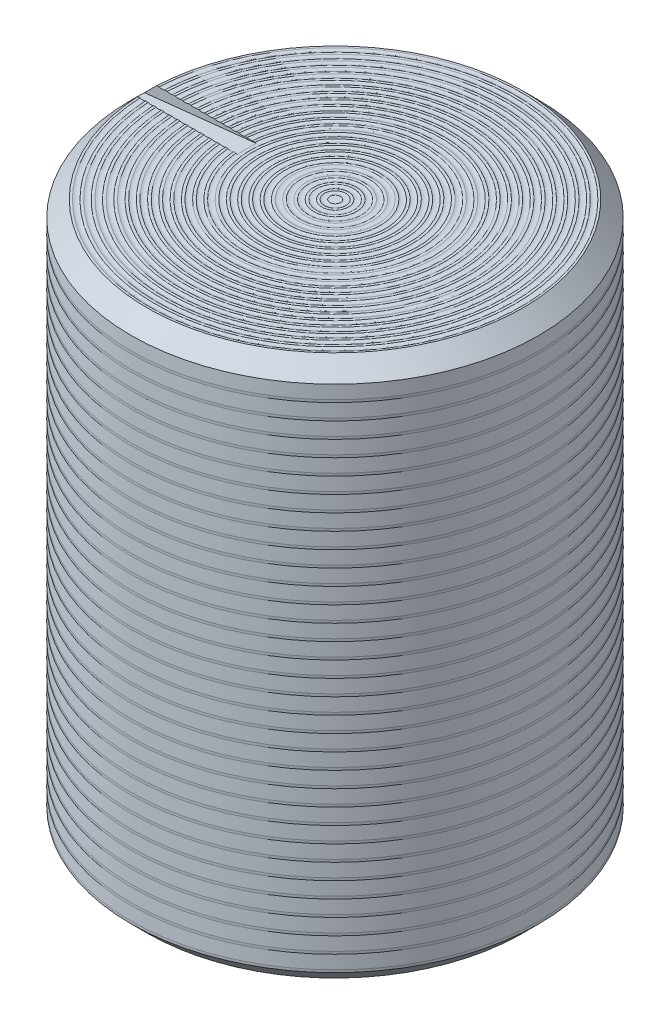
from build123d import *

# Parameters (mm, degrees)
SKETCH1_R           = 6.4
BOSS_EXTRUDE1_DEPTH = 17
CHAMFER1_SIZE       = 0.5
CUT_EXTRUDE1_DEPTH  = 0.3
SKETCH4_R           = 5.5
CUT_EXTRUDE2_DEPTH  = 16.5


with BuildPart() as part:
    # Sketch1 → Boss-Extrude1 (new body)
    with BuildSketch(Plane(origin=(0, 0, 0), x_dir=(1, 0, 0), z_dir=(0, 1, 0))):
        with Locations(Location((0, 0, 0), (0, 0, 270))):
            Circle(SKETCH1_R)
    extrude(amount=BOSS_EXTRUDE1_DEPTH)

    # Chamfer1
    chamfer1_edges = [part.edges().sort_by_distance(p)[0] for p in [
        (0, 0, -6.4),
        (0, 17, -6.4),
    ]]
    chamfer(chamfer1_edges, length=CHAMFER1_SIZE)

    # Sketch2 → Cut-Extrude1 (cut, symmetric)
    with BuildSketch(Plane.XY):
        Polygon((-6.4, 16.6), (-6.4, 17), (-2.65, 17), align=None)
    extrude(amount=CUT_EXTRUDE1_DEPTH, both=True, mode=Mode.SUBTRACT)

    # Sketch3 → Cut-Revolve1 (revolve, cut)
    with BuildSketch(Plane.XY, mode=Mode.PRIVATE) as cut_revolve1_sk:
        Polygon((-6.4, 0.5785964), (-6.367367886, 1), (-6.4, 1), align=None)
        Polygon((-6.4, 1.0785964), (-6.367367886, 1.5), (-6.4, 1.5), align=None)
        Polygon((-6.4, 1.5785964), (-6.367367886, 2), (-6.4, 2), align=None)
        Polygon((-6.4, 2.0785964), (-6.367367886, 2.5), (-6.4, 2.5), align=None)
        Polygon((-6.4, 2.5785964), (-6.367367886, 3), (-6.4, 3), align=None)
        Polygon((-6.4, 3.0785964), (-6.367367886, 3.5), (-6.4, 3.5), align=None)
        Polygon((-6.4, 3.5785964), (-6.367367886, 4), (-6.4, 4), align=None)
        Polygon((-6.4, 4.0785964), (-6.367367886, 4.5), (-6.4, 4.5), align=None)
        Polygon((-6.4, 4.5785964), (-6.367367886, 5), (-6.4, 5), align=None)
        Polygon((-6.4, 5.0785964), (-6.367367886, 5.5), (-6.4, 5.5), align=None)
        Polygon((-6.4, 5.5785964), (-6.367367886, 6), (-6.4, 6), align=None)
        Polygon((-6.4, 6.0785964), (-6.367367886, 6.5), (-6.4, 6.5), align=None)
        Polygon((-6.4, 6.5785964), (-6.367367886, 7), (-6.4, 7), align=None)
        Polygon((-6.4, 7.0785964), (-6.367367886, 7.5), (-6.4, 7.5), align=None)
        Polygon((-6.4, 7.5785964), (-6.367367886, 8), (-6.4, 8), align=None)
        Polygon((-6.4, 8.0785964), (-6.367367886, 8.5), (-6.4, 8.5), align=None)
        Polygon((-6.4, 8.5785964), (-6.367367886, 9), (-6.4, 9), align=None)
        Polygon((-6.4, 9.0785964), (-6.367367886, 9.5), (-6.4, 9.5), align=None)
        Polygon((-6.4, 9.5785964), (-6.367367886, 10), (-6.4, 10), align=None)
        Polygon((-6.4, 10.0785964), (-6.367367886, 10.5), (-6.4, 10.5), align=None)
        Polygon((-6.4, 10.5785964), (-6.367367886, 11), (-6.4, 11), align=None)
        Polygon((-6.4, 11.0785964), (-6.367367886, 11.5), (-6.4, 11.5), align=None)
        Polygon((-6.4, 11.5785964), (-6.367367886, 12), (-6.4, 12), align=None)
        Polygon((-6.4, 12.0785964), (-6.367367886, 12.5), (-6.4, 12.5), align=None)
        Polygon((-6.4, 12.5785964), (-6.367367886, 13), (-6.4, 13), align=None)
        Polygon((-6.4, 13.0785964), (-6.367367886, 13.5), (-6.4, 13.5), align=None)
        Polygon((-6.4, 13.5785964), (-6.367367886, 14), (-6.4, 14), align=None)
        Polygon((-6.4, 14.0785964), (-6.367367886, 14.5), (-6.4, 14.5), align=None)
        Polygon((-6.4, 14.5785964), (-6.367367886, 15), (-6.4, 15), align=None)
        Polygon((-6.4, 15.0785964), (-6.367367886, 15.5), (-6.4, 15.5), align=None)
        Polygon((-6.4, 15.5785964), (-6.367367886, 16), (-6.4, 16), align=None)
        Polygon((-6.4, 16.0785964), (-6.367367886, 16.5), (-6.4, 16.5), align=None)
        Polygon((-6.4, 16.5785964), (-6.367367886, 17), (-6.4, 17), align=None)
        Polygon((-6.4, 17.0785964), (-6.367367886, 17.5), (-6.4, 17.5), align=None)
    revolve(cut_revolve1_sk.sketch.rotate(Axis((0, 0, 0), (0, 1, 0)), 270), axis=Axis((0, 0, 0), (0, 1, 0)), mode=Mode.SUBTRACT)

    # Sketch4 → Cut-Extrude2 (cut)
    with BuildSketch(Plane.XZ):
        with Locations(Location((0, 0, 0), (0, 0, 270))):
            Circle(SKETCH4_R)
    extrude(amount=-CUT_EXTRUDE2_DEPTH, mode=Mode.SUBTRACT)

    # Sketch5 → Cut-Revolve2 (revolve, cut)
    with BuildSketch(Plane.XY):
        with BuildLine():
            Line((0.169631255, 17), (0.3380008, 17))
            add(Edge.make_bspline(
                [(0.169631255, 17), (0.253816027, 16.968101837), (0.3380008, 17)],
                knots=[0, 0, 0, 1, 1, 1], degree=2))
        make_face()
        with BuildLine():
            Line((0.419631255, 17), (0.5880008, 17))
            add(Edge.make_bspline(
                [(0.419631255, 17), (0.503816027, 16.968101837), (0.5880008, 17)],
                knots=[0, 0, 0, 1, 1, 1], degree=2))
        make_face()
        with BuildLine():
            Line((0.669631255, 17), (0.8380008, 17))
            add(Edge.make_bspline(
                [(0.669631255, 17), (0.753816027, 16.968101837), (0.8380008, 17)],
                knots=[0, 0, 0, 1, 1, 1], degree=2))
        make_face()
        with BuildLine():
            Line((0.919631255, 17), (1.0880008, 17))
            add(Edge.make_bspline(
                [(0.919631255, 17), (1.003816027, 16.968101837), (1.0880008, 17)],
                knots=[0, 0, 0, 1, 1, 1], degree=2))
        make_face()
        with BuildLine():
            Line((1.169631255, 17), (1.3380008, 17))
            add(Edge.make_bspline(
                [(1.169631255, 17), (1.253816027, 16.968101837), (1.3380008, 17)],
                knots=[0, 0, 0, 1, 1, 1], degree=2))
        make_face()
        with BuildLine():
            Line((1.419631255, 17), (1.5880008, 17))
            add(Edge.make_bspline(
                [(1.419631255, 17), (1.503816027, 16.968101837), (1.5880008, 17)],
                knots=[0, 0, 0, 1, 1, 1], degree=2))
        make_face()
        with BuildLine():
            Line((1.669631255, 17), (1.8380008, 17))
            add(Edge.make_bspline(
                [(1.669631255, 17), (1.753816027, 16.968101837), (1.8380008, 17)],
                knots=[0, 0, 0, 1, 1, 1], degree=2))
        make_face()
        with BuildLine():
            Line((1.919631255, 17), (2.0880008, 17))
            add(Edge.make_bspline(
                [(1.919631255, 17), (2.003816027, 16.968101837), (2.0880008, 17)],
                knots=[0, 0, 0, 1, 1, 1], degree=2))
        make_face()
        with BuildLine():
            Line((2.169631255, 17), (2.3380008, 17))
            add(Edge.make_bspline(
                [(2.169631255, 17), (2.253816027, 16.968101837), (2.3380008, 17)],
                knots=[0, 0, 0, 1, 1, 1], degree=2))
        make_face()
        with BuildLine():
            Line((2.419631255, 17), (2.5880008, 17))
            add(Edge.make_bspline(
                [(2.419631255, 17), (2.503816027, 16.968101837), (2.5880008, 17)],
                knots=[0, 0, 0, 1, 1, 1], degree=2))
        make_face()
        with BuildLine():
            Line((2.669631255, 17), (2.8380008, 17))
            add(Edge.make_bspline(
                [(2.669631255, 17), (2.753816027, 16.968101837), (2.8380008, 17)],
                knots=[0, 0, 0, 1, 1, 1], degree=2))
        make_face()
        with BuildLine():
            Line((2.919631255, 17), (3.0880008, 17))
            add(Edge.make_bspline(
                [(2.919631255, 17), (3.003816027, 16.968101837), (3.0880008, 17)],
                knots=[0, 0, 0, 1, 1, 1], degree=2))
        make_face()
        with BuildLine():
            Line((3.169631255, 17), (3.3380008, 17))
            add(Edge.make_bspline(
                [(3.169631255, 17), (3.253816027, 16.968101837), (3.3380008, 17)],
                knots=[0, 0, 0, 1, 1, 1], degree=2))
        make_face()
        with BuildLine():
            Line((3.419631255, 17), (3.5880008, 17))
            add(Edge.make_bspline(
                [(3.419631255, 17), (3.503816027, 16.968101837), (3.5880008, 17)],
                knots=[0, 0, 0, 1, 1, 1], degree=2))
        make_face()
        with BuildLine():
            Line((3.669631255, 17), (3.8380008, 17))
            add(Edge.make_bspline(
                [(3.669631255, 17), (3.753816027, 16.968101837), (3.8380008, 17)],
                knots=[0, 0, 0, 1, 1, 1], degree=2))
        make_face()
        with BuildLine():
            Line((3.919631255, 17), (4.0880008, 17))
            add(Edge.make_bspline(
                [(3.919631255, 17), (4.003816027, 16.968101837), (4.0880008, 17)],
                knots=[0, 0, 0, 1, 1, 1], degree=2))
        make_face()
        with BuildLine():
            Line((4.169631255, 17), (4.3380008, 17))
            add(Edge.make_bspline(
                [(4.169631255, 17), (4.253816027, 16.968101837), (4.3380008, 17)],
                knots=[0, 0, 0, 1, 1, 1], degree=2))
        make_face()
        with BuildLine():
            Line((4.419631255, 17), (4.5880008, 17))
            add(Edge.make_bspline(
                [(4.419631255, 17), (4.503816027, 16.968101837), (4.5880008, 17)],
                knots=[0, 0, 0, 1, 1, 1], degree=2))
        make_face()
        with BuildLine():
            Line((4.669631255, 17), (4.8380008, 17))
            add(Edge.make_bspline(
                [(4.669631255, 17), (4.753816027, 16.968101837), (4.8380008, 17)],
                knots=[0, 0, 0, 1, 1, 1], degree=2))
        make_face()
        with BuildLine():
            Line((4.919631255, 17), (5.0880008, 17))
            add(Edge.make_bspline(
                [(4.919631255, 17), (5.003816027, 16.968101837), (5.0880008, 17)],
                knots=[0, 0, 0, 1, 1, 1], degree=2))
        make_face()
        with BuildLine():
            Line((5.169631255, 17), (5.3380008, 17))
            add(Edge.make_bspline(
                [(5.169631255, 17), (5.253816027, 16.968101837), (5.3380008, 17)],
                knots=[0, 0, 0, 1, 1, 1], degree=2))
        make_face()
        with BuildLine():
            Line((5.419631255, 17), (5.5880008, 17))
            add(Edge.make_bspline(
                [(5.419631255, 17), (5.503816027, 16.968101837), (5.5880008, 17)],
                knots=[0, 0, 0, 1, 1, 1], degree=2))
        make_face()
        with BuildLine():
            Line((5.669631255, 17), (5.8380008, 17))
            add(Edge.make_bspline(
                [(5.669631255, 17), (5.753816027, 16.968101837), (5.8380008, 17)],
                knots=[0, 0, 0, 1, 1, 1], degree=2))
        make_face()
        with BuildLine():
            Line((5.919631255, 17), (6.0880008, 17))
            add(Edge.make_bspline(
                [(5.919631255, 17), (6.003816027, 16.968101837), (6.0880008, 17)],
                knots=[0, 0, 0, 1, 1, 1], degree=2))
        make_face()
        with BuildLine():
            Line((6.169631255, 17), (6.3380008, 17))
            add(Edge.make_bspline(
                [(6.169631255, 17), (6.253816027, 16.968101837), (6.3380008, 17)],
                knots=[0, 0, 0, 1, 1, 1], degree=2))
        make_face()
        with BuildLine():
            Line((6.419631255, 17), (6.5880008, 17))
            add(Edge.make_bspline(
                [(6.419631255, 17), (6.503816027, 16.968101837), (6.5880008, 17)],
                knots=[0, 0, 0, 1, 1, 1], degree=2))
        make_face()
        with BuildLine():
            Line((6.669631255, 17), (6.8380008, 17))
            add(Edge.make_bspline(
                [(6.669631255, 17), (6.753816027, 16.968101837), (6.8380008, 17)],
                knots=[0, 0, 0, 1, 1, 1], degree=2))
        make_face()
        with BuildLine():
            Line((6.919631255, 17), (7.0880008, 17))
            add(Edge.make_bspline(
                [(6.919631255, 17), (7.003816027, 16.968101837), (7.0880008, 17)],
                knots=[0, 0, 0, 1, 1, 1], degree=2))
        make_face()
        with BuildLine():
            Line((7.169631255, 17), (7.3380008, 17))
            add(Edge.make_bspline(
                [(7.169631255, 17), (7.253816027, 16.968101837), (7.3380008, 17)],
                knots=[0, 0, 0, 1, 1, 1], degree=2))
        make_face()
        with BuildLine():
            Line((7.419631255, 17), (7.5880008, 17))
            add(Edge.make_bspline(
                [(7.419631255, 17), (7.503816027, 16.968101837), (7.5880008, 17)],
                knots=[0, 0, 0, 1, 1, 1], degree=2))
        make_face()
    revolve(axis=Axis((0.003816027, 17, 0), (0, 1, 0)), mode=Mode.SUBTRACT)


solid = part.part
